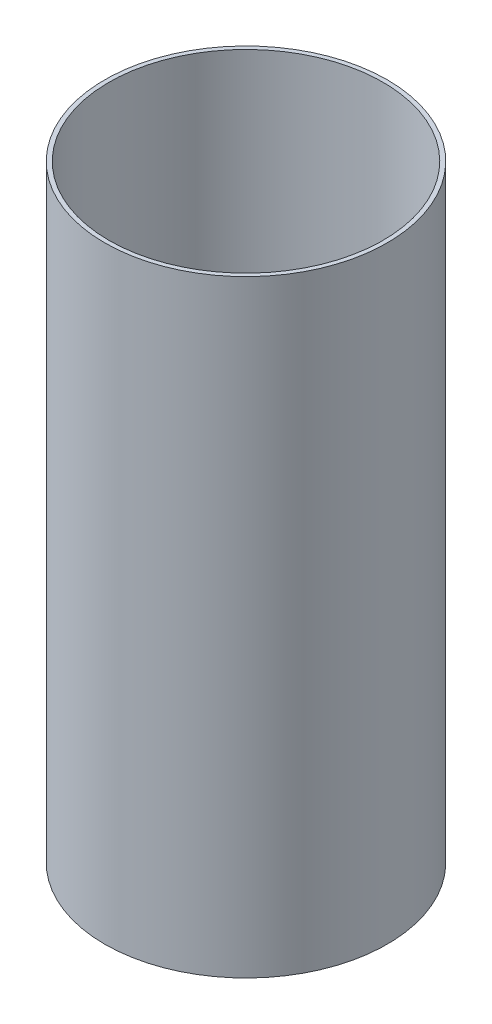
from build123d import *

# Parameters (mm, degrees)
SKETCH1_R           = 63.5
SKETCH1_R_2         = 61.595
BOSS_EXTRUDE1_DEPTH = 136.525


with BuildPart() as part:
    # Sketch1 → Boss-Extrude1 (new body, symmetric)
    with BuildSketch(Plane(origin=(0, 0, 0), x_dir=(1, 0, 0), z_dir=(0, 1, 0))):
        Circle(SKETCH1_R)
        Circle(SKETCH1_R_2, mode=Mode.SUBTRACT)
    extrude(amount=BOSS_EXTRUDE1_DEPTH, both=True)


solid = part.part
